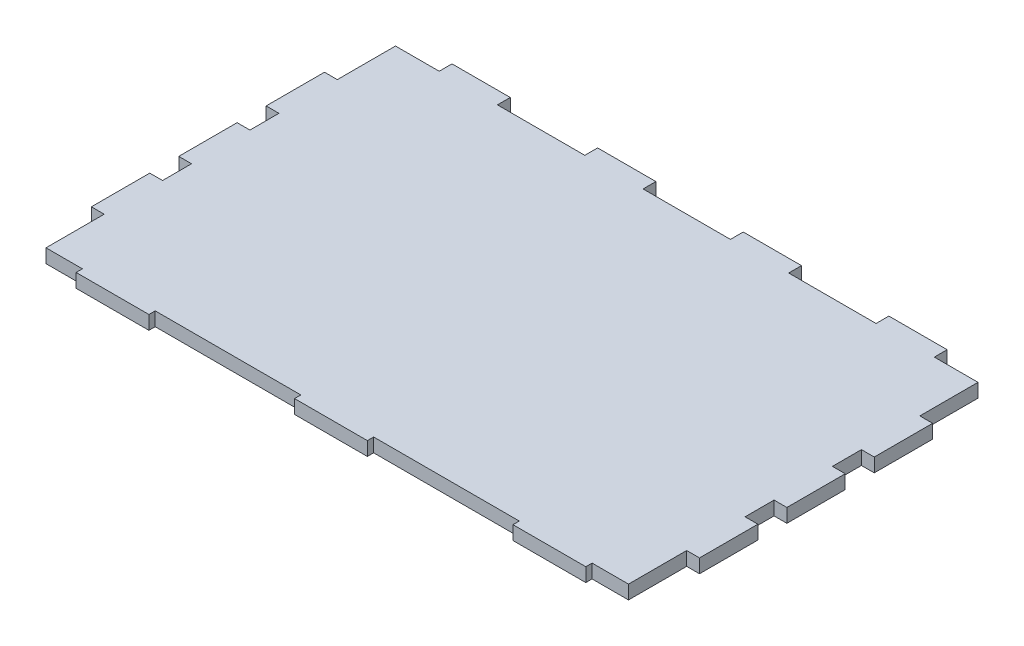
from build123d import *

# Parameters (mm, degrees)
SKETCH1_W             = 254
SKETCH1_H             = 152.4
BOSS_EXTRUDE1_DEPTH   = 6
SKETCH2_W             = 25.4
SKETCH2_H             = 5.588
SKETCH2_W_2           = 31.75
SKETCH2_H_2           = 2.7432
TABS_TOP_BOTTOM_DEPTH = 6
SKETCH3_W             = 5.588
SKETCH3_H             = 25.4508
TABS_SIDE_DEPTH       = 6


with BuildPart() as part:
    # Sketch1 → Boss-Extrude1 (new body)
    with BuildSketch(Plane(origin=(0, 0, 0), x_dir=(1, 0, 0), z_dir=(0, 1, 0))):
        Rectangle(SKETCH1_W, SKETCH1_H)
    extrude(amount=BOSS_EXTRUDE1_DEPTH)

    # Sketch2 → Tabs - Top/Bottom (add)
    with BuildSketch(Plane(origin=(0, 6, 0), x_dir=(1, 0, 0), z_dir=(0, 1, 0))):
        with Locations((95.25, 78.994)):
            Rectangle(SKETCH2_W, SKETCH2_H)
        with Locations((-95.25, 78.994)):
            Rectangle(SKETCH2_W, SKETCH2_H)
        with Locations((-31.75, 78.994)):
            Rectangle(SKETCH2_W, SKETCH2_H)
        with Locations((31.75, 78.994)):
            Rectangle(SKETCH2_W, SKETCH2_H)
        with Locations((-95.25, -77.5716)):
            Rectangle(SKETCH2_W_2, SKETCH2_H_2)
        with Locations((0, -77.5716)):
            Rectangle(SKETCH2_W_2, SKETCH2_H_2)
        with Locations((95.25, -77.5716)):
            Rectangle(SKETCH2_W_2, SKETCH2_H_2)
    extrude(amount=-TABS_TOP_BOTTOM_DEPTH)

    # Sketch3 → Tabs - Side (add)
    with BuildSketch(Plane(origin=(0, 6, 0), x_dir=(1, 0, 0), z_dir=(0, 1, 0))):
        with Locations((-129.794, -38.1)):
            Rectangle(SKETCH3_W, SKETCH3_H)
        with Locations((-129.794, 0)):
            Rectangle(SKETCH3_W, SKETCH3_H)
        with Locations((-129.794, 38.1)):
            Rectangle(SKETCH3_W, SKETCH3_H)
        with Locations((129.794, -38.1)):
            Rectangle(SKETCH3_W, SKETCH3_H)
        with Locations((129.794, 38.1)):
            Rectangle(SKETCH3_W, SKETCH3_H)
        with Locations((129.794, 0)):
            Rectangle(SKETCH3_W, SKETCH3_H)
    extrude(amount=-TABS_SIDE_DEPTH)


solid = part.part
